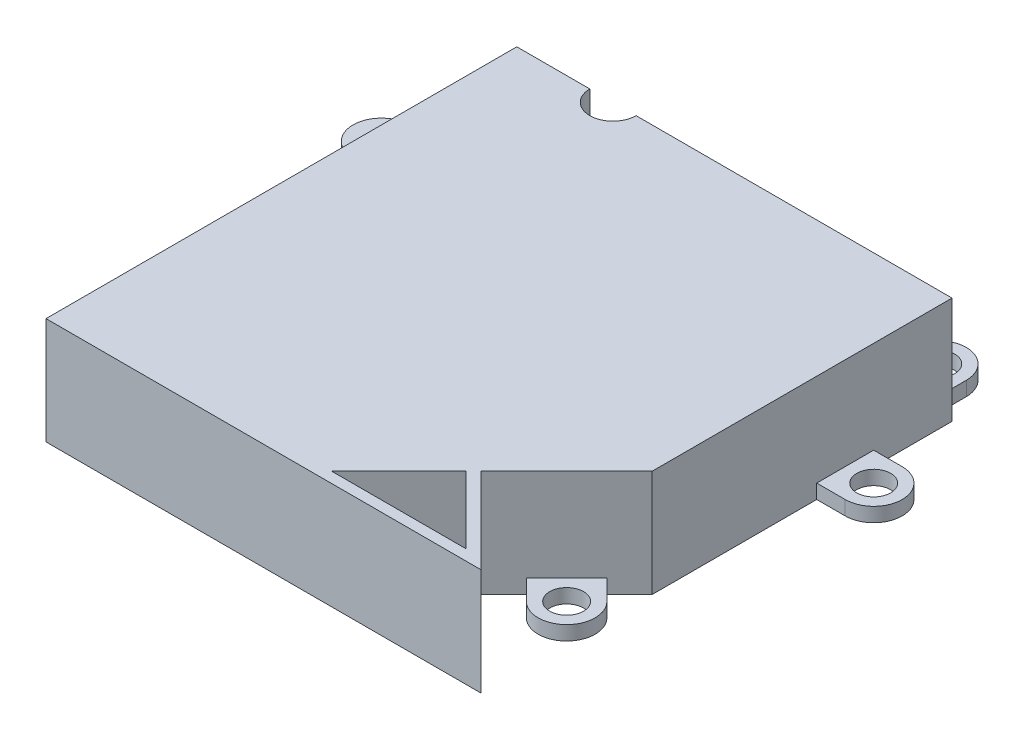
from build123d import *

# Parameters (mm, degrees)
BOSS_EXTRUDE2_DEPTH  = 15
CUT_EXTRUDE1_DEPTH   = 13.5
SKETCH4_W            = 22
SKETCH4_H            = 1.5
CUT_EXTRUDE2_DEPTH   = 7.5
CUT_EXTRUDE3_DEPTH   = 1.5
CUT_EXTRUDE4_DEPTH   = 10
SKETCH21_W           = 1.5
SKETCH21_H           = 63.1126
BOSS_EXTRUDE6_DEPTH  = 13.5
CUT_EXTRUDE7_DEPTH   = 16
BOSS_EXTRUDE7_DEPTH  = 2
BOSS_EXTRUDE8_DEPTH  = 2
BOSS_EXTRUDE9_DEPTH  = 2
BOSS_EXTRUDE10_DEPTH = 9
SKETCH29_R           = 2.38125
CUT_EXTRUDE8_DEPTH   = 16
SKETCH31_R           = 2.38125
CUT_EXTRUDE9_DEPTH   = 6.35


with BuildPart() as part:
    # Sketch2 → Boss-Extrude2 (new body)
    with BuildSketch(Plane(origin=(0, 0, 0), x_dir=(1, 0, 0), z_dir=(0, 1, 0))):
        Polygon((40.1244, 0), (0, 0), (0, 66.1126), (64.116, 66.1126), (64.116, 23.9916), align=None)
        Polygon((41.6244, 1.5), (40.1244, 0), (64.116, 0), (52.1202, 11.9958), (51.059539828, 10.935139828), (60.494679656, 1.5), align=None)
    extrude(amount=BOSS_EXTRUDE2_DEPTH)

    # Sketch3 → Cut-Extrude1 (cut)
    with BuildSketch(Plane.XZ):
        Polygon((1.5, -64.6126), (62.616, -64.6126), (62.616, -24.612920344), (39.503079656, -1.5), (1.5, -1.5), align=None)
    extrude(amount=-CUT_EXTRUDE1_DEPTH, mode=Mode.SUBTRACT)

    # Sketch4 → Cut-Extrude2 (cut)
    with BuildSketch(Plane.XZ):
        with Locations((30.616, -65.3626)):
            Rectangle(SKETCH4_W, SKETCH4_H)
    extrude(amount=-CUT_EXTRUDE2_DEPTH, mode=Mode.SUBTRACT)

    # Sketch16 → Cut-Extrude3 (cut)
    with BuildSketch(Plane(origin=(0, 0, -66.1126), x_dir=(-1, 0, 0), z_dir=(0, 0, -1))):
        Polygon((-19.616, 0), (-9.616, 0), (-9.616, 9.5), (-54.116, 9.5), (-54.116, 0), (-41.616, 0), (-41.616, 7.5), (-19.616, 7.5), align=None)
    extrude(amount=-CUT_EXTRUDE3_DEPTH, mode=Mode.SUBTRACT)

    # Sketch18 → Cut-Extrude4 (cut)
    with BuildSketch(Plane(origin=(0, 15, 0), x_dir=(1, 0, 0), z_dir=(0, 1, 0))):
        with BuildLine():
            ThreePointArc((19.75, 66.1126), (16.5, 69.3626), (13.25, 66.1126))
            Line((13.25, 66.1126), (16.5, 66.1126))
            Line((16.5, 66.1126), (19.75, 66.1126))
        make_face()
        with BuildLine():
            Line((16.5, 66.1126), (13.25, 66.1126))
            ThreePointArc((13.25, 66.1126), (16.5, 62.8626), (19.75, 66.1126))
            Line((19.75, 66.1126), (16.5, 66.1126))
        make_face()
    extrude(amount=-CUT_EXTRUDE4_DEPTH, mode=Mode.SUBTRACT)

    # Sketch21 → Boss-Extrude6 (add)
    with BuildSketch(Plane.XZ):
        with Locations((3.75, -33.0563)):
            Rectangle(SKETCH21_W, SKETCH21_H)
    extrude(amount=-BOSS_EXTRUDE6_DEPTH)

    # Sketch24 → Cut-Extrude7 (cut, through all)
    with BuildSketch(Plane.XZ):
        Polygon((3, -1.5), (3, 0), (0, 0), (0, -66.1126), (3, -66.1126), align=None)
    extrude(amount=-CUT_EXTRUDE7_DEPTH, mode=Mode.SUBTRACT)

    # Sketch25 → Boss-Extrude7 (add)
    with BuildSketch(Plane.XZ):
        with BuildLine():
            Line((62.116, -70.1126), (62.116, -66.1126))
            Line((62.116, -66.1126), (58.116, -66.1126))
            Line((58.116, -66.1126), (54.116, -66.1126))
            Line((54.116, -66.1126), (54.116, -70.1126))
            ThreePointArc((54.116, -70.1126), (58.116, -74.1126), (62.116, -70.1126))
        make_face()
    extrude(amount=-BOSS_EXTRUDE7_DEPTH)

    # Sketch26 → Boss-Extrude8 (add)
    with BuildSketch(Plane.XZ):
        with BuildLine():
            Line((64.116, -51.1126), (64.116, -55.1126))
            Line((64.116, -55.1126), (68.116, -55.1126))
            ThreePointArc((68.116, -55.1126), (72.116, -51.1126), (68.116, -47.1126))
            Line((68.116, -47.1126), (64.116, -47.1126))
            Line((64.116, -47.1126), (64.116, -51.1126))
        make_face()
    extrude(amount=-BOSS_EXTRUDE8_DEPTH)

    # Sketch27 → Boss-Extrude9 (add)
    with BuildSketch(Plane.XZ):
        with BuildLine():
            ThreePointArc((63.774954249, -17.9937), (63.774954249, -12.336845751), (58.1181, -12.336845751))
            Line((58.1181, -12.336845751), (55.289672875, -15.165272875))
            Line((55.289672875, -15.165272875), (58.1181, -17.9937))
            Line((58.1181, -17.9937), (60.946527125, -20.822127125))
            Line((60.946527125, -20.822127125), (63.774954249, -17.9937))
        make_face()
    extrude(amount=-BOSS_EXTRUDE9_DEPTH)

    # Sketch28 → Boss-Extrude10 (add)
    with BuildSketch(Plane.XZ):
        with BuildLine():
            Line((-1, -55.1126), (3, -55.1126))
            Line((3, -55.1126), (3, -51.1126))
            Line((3, -51.1126), (3, -47.1126))
            Line((3, -47.1126), (-1, -47.1126))
            ThreePointArc((-1, -47.1126), (-5, -51.1126), (-1, -55.1126))
        make_face()
    extrude(amount=-BOSS_EXTRUDE10_DEPTH)

    # Sketch29 → Cut-Extrude8 (cut, through all)
    with BuildSketch(Plane.XZ):
        with Locations((60.946527125, -15.165272875)):
            Circle(SKETCH29_R)
        with Locations((68.116, -51.1126)):
            Circle(SKETCH29_R)
        with Locations((58.116, -70.1126)):
            Circle(SKETCH29_R)
    extrude(amount=-CUT_EXTRUDE8_DEPTH, mode=Mode.SUBTRACT)

    # Sketch31 → Cut-Extrude9 (cut)
    with BuildSketch(Plane.XZ):
        with Locations((-1, -51.1126)):
            Circle(SKETCH31_R)
    extrude(amount=-CUT_EXTRUDE9_DEPTH, mode=Mode.SUBTRACT)


solid = part.part
